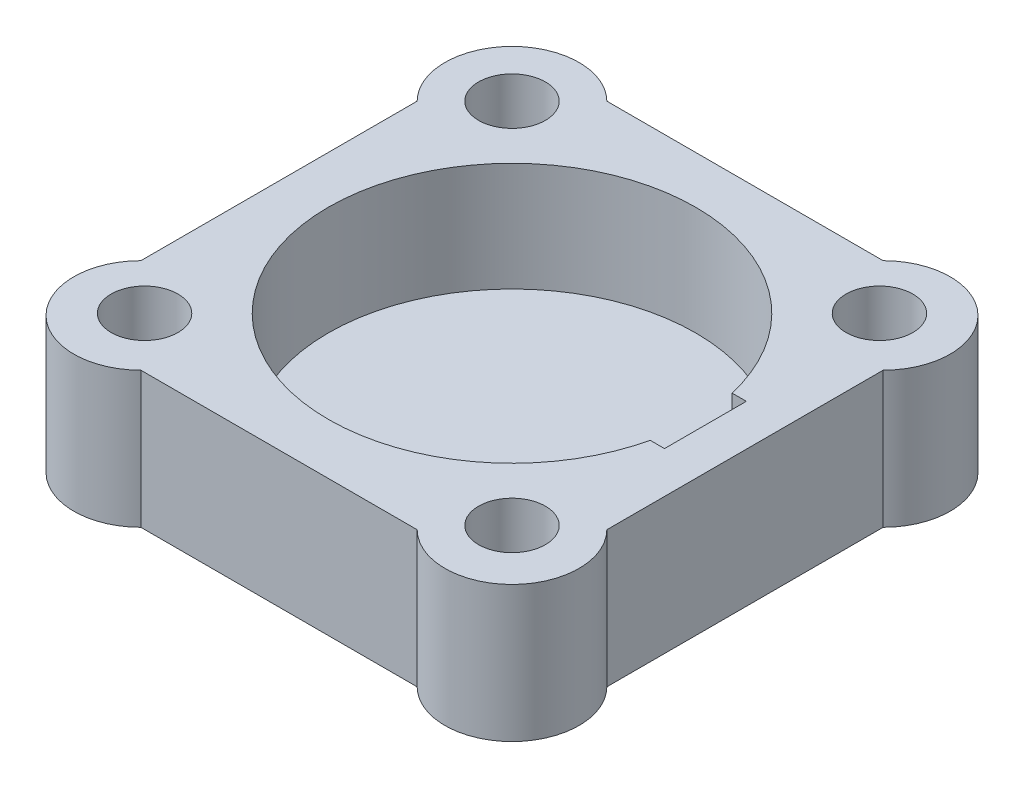
from build123d import *

# Parameters (mm, degrees)
SKETCH1_R               = 20.25
SKETCH1_R_2             = 3.682229715
BOSS_EXTRUDE1_DEPTH     = 15
SKETCH2_R               = 20.25
BOSS_EXTRUDE2_DEPTH     = 3
SKETCH3_W               = 2.140111698
SKETCH3_H               = 9.021804968
CUT_EXTRUDE1_DEPTH      = 13
CUT_EXTRUDE1_DEPTH_BACK = 4


with BuildPart() as part:
    # Sketch1 → Boss-Extrude1 (new body)
    with BuildSketch(Plane(origin=(0, 0, 0), x_dir=(1, 0, 0), z_dir=(0, 1, 0))):
        with BuildLine():
            Line((-25.477303851, -15.433164228), (-25.477303851, 15.022696149))
            ThreePointArc((-25.477303851, 15.022696149), (-25.477303851, 25.477303851), (-15.022696149, 25.477303851))
            Line((-15.022696149, 25.477303851), (15.433164228, 25.477303851))
            ThreePointArc((15.433164228, 25.477303851), (25.887771929, 25.477303851), (25.887771929, 15.022696149))
            Line((25.887771929, 15.022696149), (25.887771929, -15.433164228))
            ThreePointArc((25.887771929, -15.433164228), (25.887771929, -25.887771929), (15.433164228, -25.887771929))
            Line((15.433164228, -25.887771929), (-15.022696149, -25.887771929))
            ThreePointArc((-15.022696149, -25.887771929), (-25.477303851, -25.887771929), (-25.477303851, -15.433164228))
        make_face()
        Circle(SKETCH1_R, mode=Mode.SUBTRACT)
        with Locations((-20.25, 20.25)):
            Circle(SKETCH1_R_2, mode=Mode.SUBTRACT)
        with Locations((20.25, 20.25)):
            Circle(SKETCH1_R_2, mode=Mode.SUBTRACT)
        with Locations((20.25, -20.25)):
            Circle(SKETCH1_R_2, mode=Mode.SUBTRACT)
        with Locations((-20.25, -20.25)):
            Circle(SKETCH1_R_2, mode=Mode.SUBTRACT)
    extrude(amount=BOSS_EXTRUDE1_DEPTH)

    # Sketch2 → Boss-Extrude2 (add)
    with BuildSketch(Plane.XZ):
        Circle(SKETCH2_R)
    extrude(amount=-BOSS_EXTRUDE2_DEPTH)

    # Sketch3 → Cut-Extrude1 (cut, two sides)
    with BuildSketch(Plane(origin=(0, 3, 0), x_dir=(1, 0, 0), z_dir=(0, 1, 0))) as cut_extrude1_sk:
        with Locations((20.25, 0)):
            Rectangle(SKETCH3_W, SKETCH3_H)
    extrude(amount=CUT_EXTRUDE1_DEPTH, mode=Mode.SUBTRACT)
    extrude(cut_extrude1_sk.sketch, amount=-CUT_EXTRUDE1_DEPTH_BACK, mode=Mode.SUBTRACT)


solid = part.part
